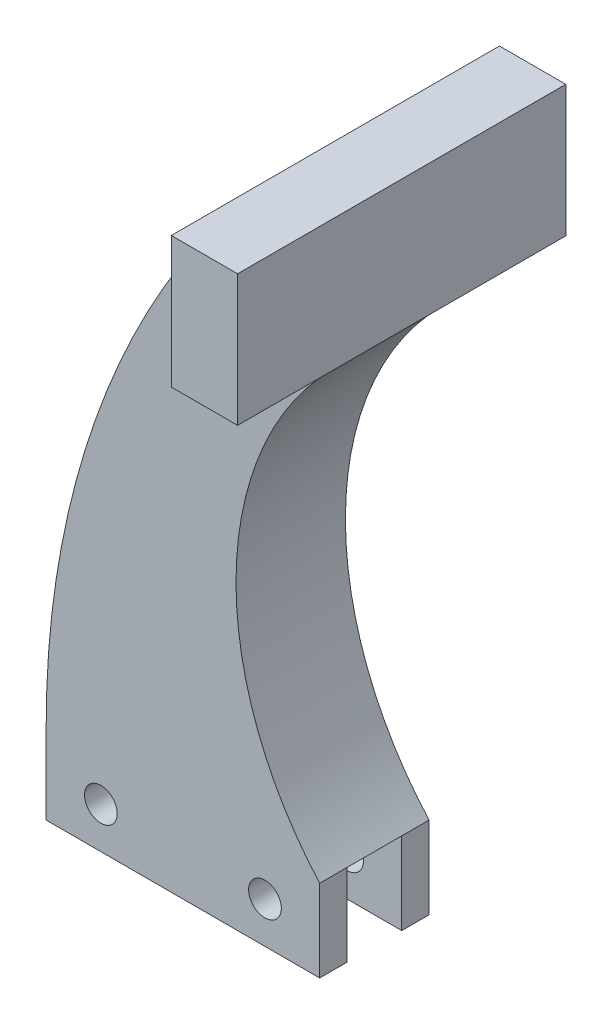
from build123d import *

# Parameters (mm, degrees)
BOSS_EXTRUDE1_DEPTH   = 12.7
SKETCH5_W             = 6.35
SKETCH5_H             = 9.525
CUT_EXTRUDE1_DEPTH    = 35.925
F_6_CLEARANCE_HOLE1_D = 3.7973
SKETCH9_W             = 7.701365702
SKETCH9_H             = 15.24
BOSS_EXTRUDE2_DEPTH   = 19.05


with BuildPart() as part:
    # Sketch1 → Boss-Extrude1 (new body)
    with BuildSketch(Plane.XY):
        with BuildLine():
            Line((-15.875, 0), (15.875, 0))
            Line((15.875, 0), (15.875, 9.525))
            ThreePointArc((15.875, 9.525), (6.228979432, 37.173295328), (19.05, 63.5))
            Line((19.05, 63.5), (19.05, 78.74))
            Line((19.05, 78.74), (11.348634298, 78.74))
            ThreePointArc((11.348634298, 78.74), (-8.824454666, 46.71317853), (-15.875, 9.525))
            Line((-15.875, 9.525), (-15.875, 0))
        make_face()
    extrude(amount=-BOSS_EXTRUDE1_DEPTH)

    # Sketch5 → Cut-Extrude1 (cut, through all)
    with BuildSketch(Plane.ZY.offset(15.875)):
        with Locations((-6.35, 4.7625)):
            Rectangle(SKETCH5_W, SKETCH5_H)
    extrude(amount=-CUT_EXTRUDE1_DEPTH, mode=Mode.SUBTRACT)

    # #6 Clearance Hole1 (through all)
    with Locations(Plane.XY):
        with Locations((9.525, 4.7625), (-9.525, 4.7625)):
            Hole(F_6_CLEARANCE_HOLE1_D / 2)

    # Sketch9 → Boss-Extrude2 (add, symmetric)
    with BuildSketch(Plane.XY.offset(-6.35)):
        with Locations((15.199317149, 71.12)):
            Rectangle(SKETCH9_W, SKETCH9_H)
    extrude(amount=BOSS_EXTRUDE2_DEPTH, both=True)


solid = part.part
